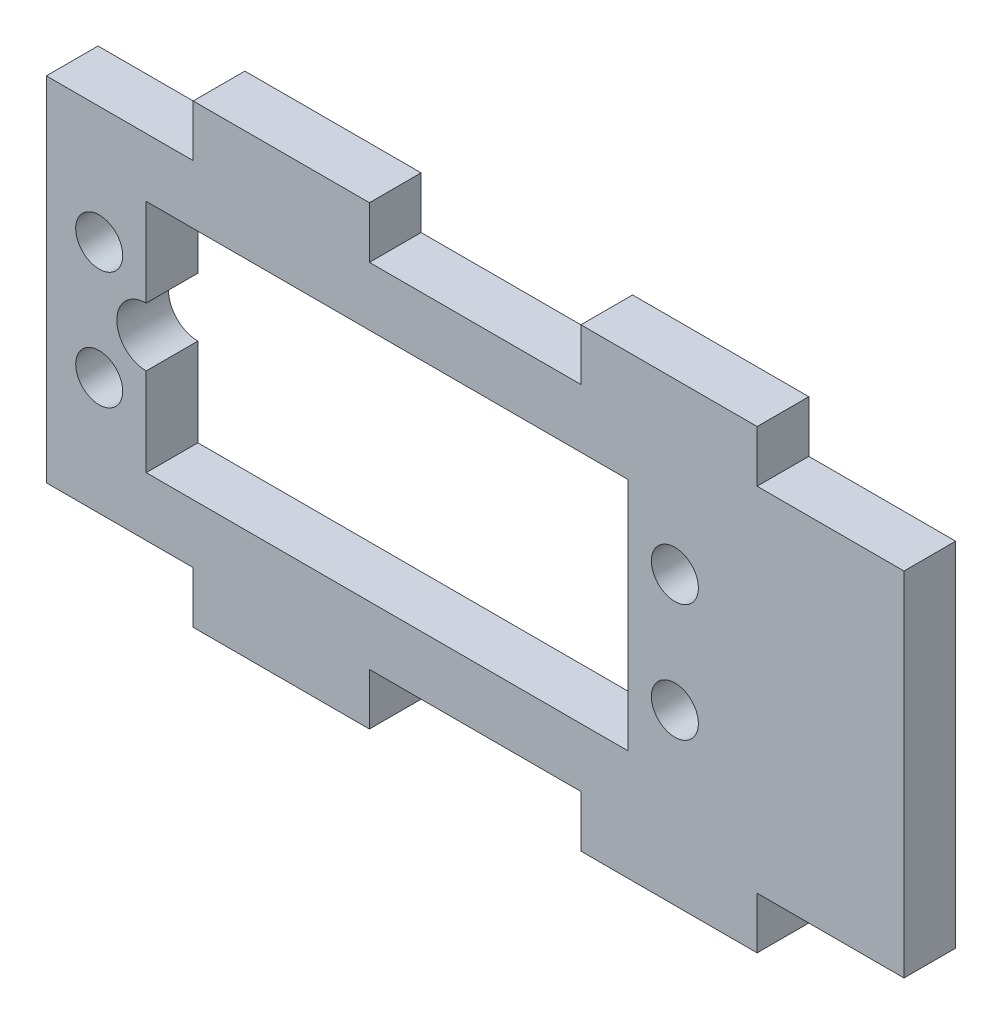
from build123d import *

# Parameters (mm, degrees)
SKETCH_1_R          = 2
SKETCH_1_W          = 41
SKETCH_1_H          = 20
EXTRUDE_1_DEPTH     = 4.4
SKETCH_2_R          = 2.5
CUT_EXTRUDE_1_DEPTH = 4.4


with BuildPart() as part:
    # 草图1 → 凸台-拉伸1 (new body)
    with BuildSketch(Plane.XY):
        Polygon((9, 15), (9, 19.4), (24, 19.4), (24, 15), (36.5, 15), (36.5, -15), (24, -15), (24, -19.4), (9, -19.4), (9, -15), (-9, -15), (-9, -19.4), (-24, -19.4), (-24, -15), (-36.5, -15), (-36.5, 15), (-24, 15), (-24, 19.4), (-9, 19.4), (-9, 15), align=None)
        with Locations((-32, 5)):
            Circle(SKETCH_1_R, mode=Mode.SUBTRACT)
        with Locations((-32, -5)):
            Circle(SKETCH_1_R, mode=Mode.SUBTRACT)
        with Locations((17, -5)):
            Circle(SKETCH_1_R, mode=Mode.SUBTRACT)
        with Locations((17, 5)):
            Circle(SKETCH_1_R, mode=Mode.SUBTRACT)
        with Locations((-7.5, 0)):
            Rectangle(SKETCH_1_W, SKETCH_1_H, mode=Mode.SUBTRACT)
    extrude(amount=EXTRUDE_1_DEPTH)

    # 草图2 → 切除-拉伸1 (cut)
    with BuildSketch(Plane.XY.offset(4.4)):
        with Locations((-28, 0)):
            Circle(SKETCH_2_R)
    extrude(amount=-CUT_EXTRUDE_1_DEPTH, mode=Mode.SUBTRACT)


solid = part.part
